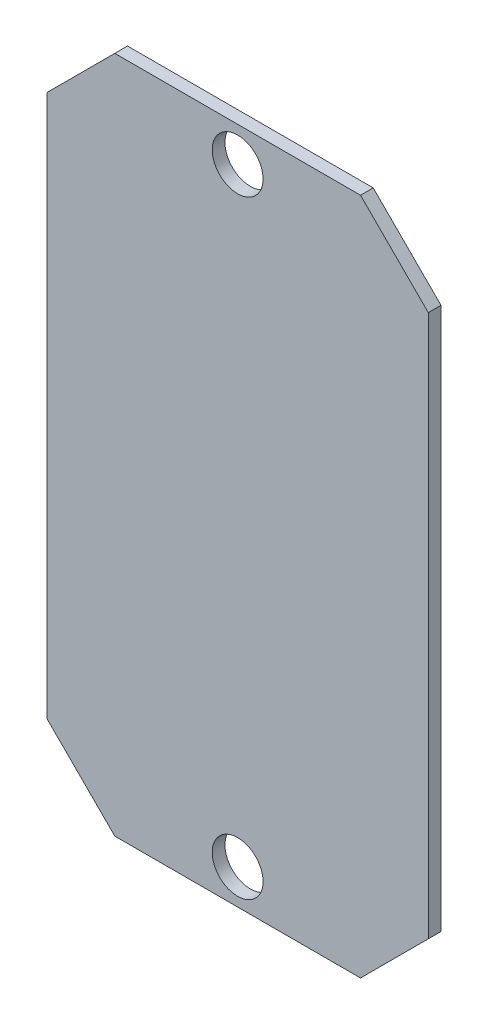
from build123d import *

# Parameters (mm, degrees)
ESQUISSE1_W             = 45
ESQUISSE1_H             = 80
BOSS_EXTRU_1_DEPTH      = 1.5
CHANFREIN1_SIZE         = 8
ESQUISSE2_R             = 3
ENL_V_MAT_EXTRU_1_DEPTH = 2.5


with BuildPart() as part:
    # Esquisse1 → Boss.-Extru.1 (new body)
    with BuildSketch(Plane.XY):
        with Locations((22.5, 40)):
            Rectangle(ESQUISSE1_W, ESQUISSE1_H)
    extrude(amount=BOSS_EXTRU_1_DEPTH)

    # Chanfrein1
    chanfrein1_edges = [part.edges().sort_by_distance(p)[0] for p in [
        (0, 80, 0.75),
        (45, 80, 0.75),
        (45, 0, 0.75),
        (0, 0, 0.75),
    ]]
    chamfer(chanfrein1_edges, length=CHANFREIN1_SIZE)

    # Esquisse2 → Enlèv. mat.-Extru.1 (cut, through all)
    with BuildSketch(Plane.XY.offset(1.5)):
        with Locations((22.5, 75.9)):
            Circle(ESQUISSE2_R)
        with Locations((22.5, 4.1)):
            Circle(ESQUISSE2_R)
    extrude(amount=-ENL_V_MAT_EXTRU_1_DEPTH, mode=Mode.SUBTRACT)


solid = part.part
